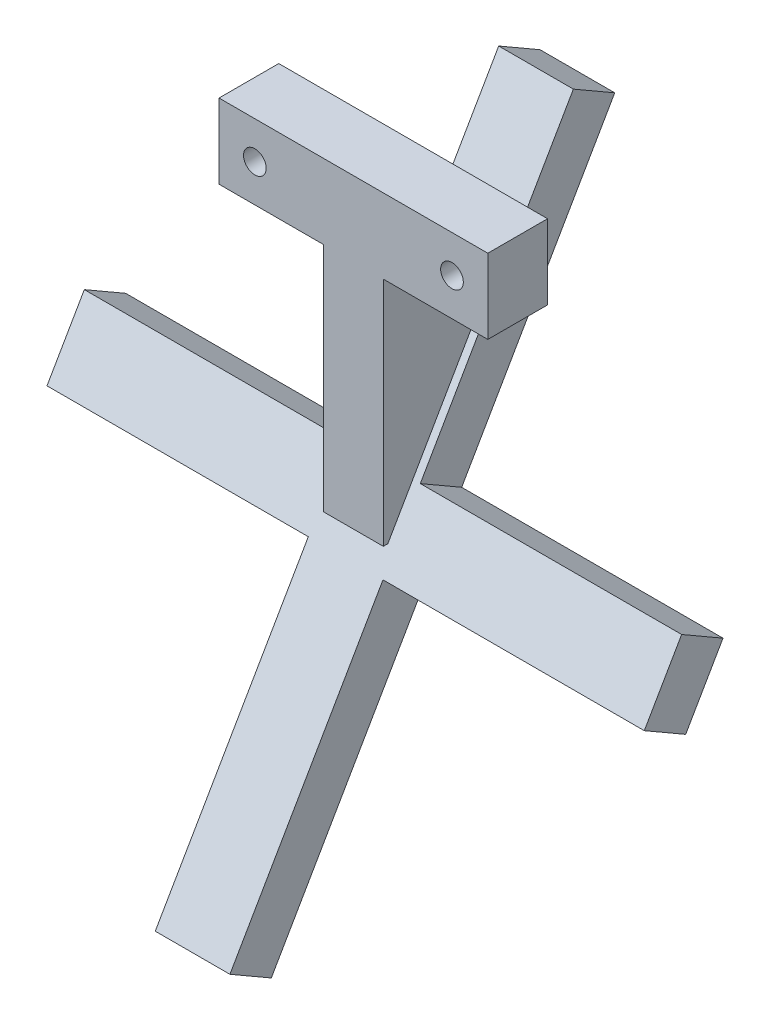
from build123d import *

# Parameters (mm, degrees)
BOSS_EXTRUDE1_DEPTH      = 22.5
BOSS_EXTRUDE1_DEPTH_BACK = 22.5
SKETCH1_W                = 10
SKETCH1_H                = 12.5
BOSS_EXTRUDE2_DEPTH      = 5
BOSS_EXTRUDE2_DEPTH_BACK = 5
SKETCH2_W                = 10
SKETCH2_H                = 38.75
F_6_CLEARANCE_HOLE1_D    = 3.7973
BOSS_EXTRUDE5_DEPTH      = 8
FILLET2_R                = 5


with BuildPart() as part:
    # Sketch1 → Boss-Extrude1 (new, two sides: drawn at the far end of the back side and taken through both)
    with BuildSketch(Plane(origin=(0, 0, 0), x_dir=(0, 0, -1), z_dir=(1, 0, 0)).offset(-BOSS_EXTRUDE1_DEPTH_BACK)):
        with Locations((12.5, 0)):
            Rectangle(SKETCH1_W, SKETCH1_H)
    extrude(amount=BOSS_EXTRUDE1_DEPTH + BOSS_EXTRUDE1_DEPTH_BACK)

    # Sketch2 → Boss-Extrude2 (add, two sides: drawn at the far end of the back side and taken through both)
    with BuildSketch(Plane(origin=(0, 0, 0), x_dir=(0, 0, -1), z_dir=(1, 0, 0)).offset(-BOSS_EXTRUDE2_DEPTH_BACK)):
        with Locations((12.5, -25.625)):
            Rectangle(SKETCH2_W, SKETCH2_H)
    extrude(amount=BOSS_EXTRUDE2_DEPTH + BOSS_EXTRUDE2_DEPTH_BACK)

    # 6 Clearance Hole1 (through all)
    with Locations(Plane(origin=(0, 0, -17.5), x_dir=(-1, 0, 0), z_dir=(0, 0, -1))):
        with Locations((16.5, 0), (-16.5, 0)):
            Hole(F_6_CLEARANCE_HOLE1_D / 2)

    # Sketch3 → Boss-Extrude5 (add)
    with BuildSketch(Plane(origin=(0, 4.290110382, -45.957658497), x_dir=(-1, 0, 0), z_dir=(0, 0.499999999999998, 0.8660254037844398))):
        Polygon((50, 53.165316994), (50, 65.665316994), (6.25, 65.665316994), (6.25, 116.915316994), (-6.25, 116.915316994), (-6.25, 65.665316994), (-50, 65.665316994), (-50, 53.165316994), (-6.25, 53.165316994), (-6.25, 1.915316994), (6.25, 1.915316994), (6.25, 53.165316994), align=None)
    extrude(amount=BOSS_EXTRUDE5_DEPTH)

    # Fillet2
    fillet2_edges = [part.edges().sort_by_distance(p)[0] for p in [
        (0, -29, -17.5),
    ]]
    fillet(fillet2_edges, radius=FILLET2_R)


solid = part.part
